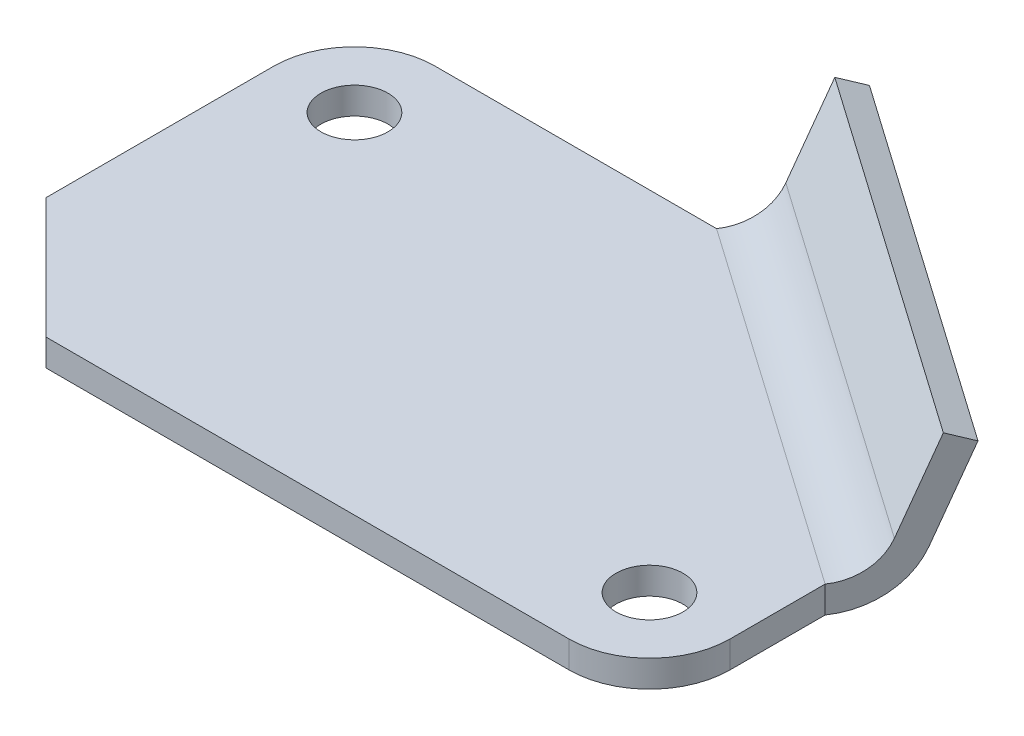
from build123d import *

# Parameters (mm, degrees)
SKETCH1_R           = 5
BOSS_EXTRUDE1_DEPTH = 4
BOSS_EXTRUDE2_DEPTH = 65.921828


with BuildPart() as part:
    # Sketch1 → Boss-Extrude1 (new body)
    with BuildSketch(Plane(origin=(0, 0, 0), x_dir=(1, 0, 0), z_dir=(0, 1, 0))):
        with BuildLine():
            Line((-12, 0), (-12, -34))
            Line((-12, -34), (6, -52))
            Line((6, -52), (84, -52))
            ThreePointArc((84, -52), (92.485281374, -48.485281374), (96, -40))
            Line((96, -40), (96, -25.811207063))
            Line((96, -25.811207063), (42, 12))
            Line((42, 12), (0, 12))
            ThreePointArc((0, 12), (-8.485281374, 8.485281374), (-12, 0))
        make_face()
        Circle(SKETCH1_R, mode=Mode.SUBTRACT)
        with Locations((84, -40)):
            Circle(SKETCH1_R, mode=Mode.SUBTRACT)
    extrude(amount=BOSS_EXTRUDE1_DEPTH)

    # Sketch3 → Boss-Extrude2 (add)
    with BuildSketch(Plane(origin=(76.544267285, 0, 53.59687296), x_dir=(0, -1, 0), z_dir=(0.819152044, 0, 0.573576436))):
        with BuildLine():
            Line((-20.485294843, 50.290733421), (-21.983721217, 46.581998003))
            Line((-21.983721217, 46.581998003), (-9.003147253, 41.337505695))
            ThreePointArc((-9.003147253, 41.337505695), (-5.36769942, 38.393578086), (-4, 33.920034858))
            Line((-4, 33.920034858), (0, 33.920034858))
            ThreePointArc((0, 33.920034858), (-2.051549129, 40.6303497), (-7.504720879, 45.046241113))
            Line((-7.504720879, 45.046241113), (-20.485294843, 50.290733421))
        make_face()
    extrude(amount=-BOSS_EXTRUDE2_DEPTH)


solid = part.part
